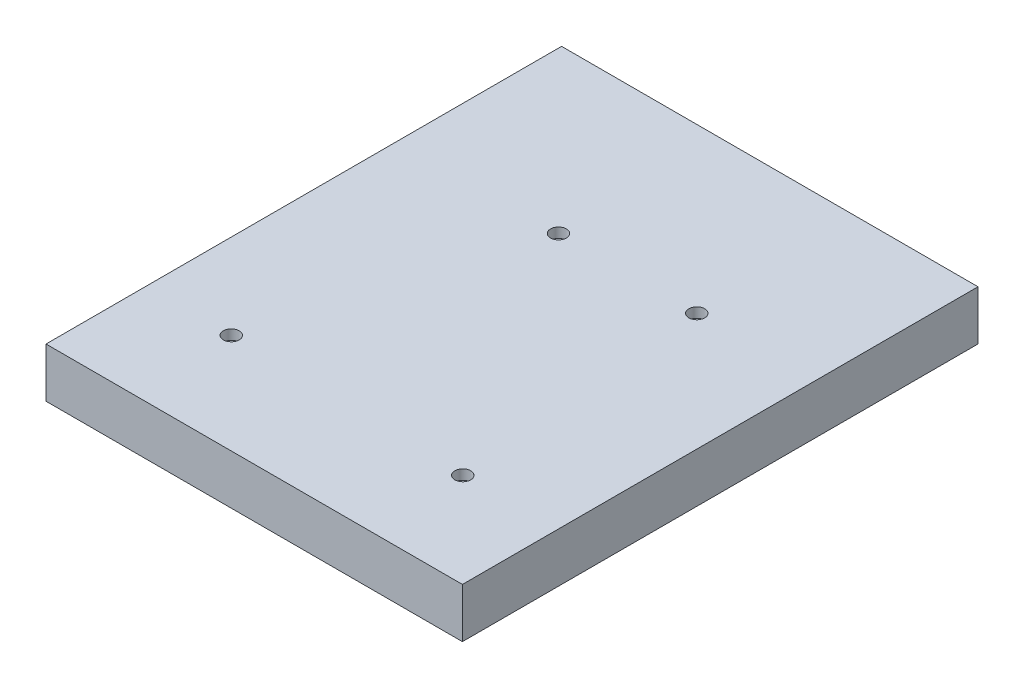
from build123d import *

# Parameters (mm, degrees)
SKETCH1_W           = 84
SKETCH1_H           = 104
BOSS_EXTRUDE1_DEPTH = 20
SKETCH2_W           = 82
SKETCH2_H           = 102
CUT_EXTRUDE1_DEPTH  = 5
SKETCH3_W           = 74
SKETCH3_H           = 94
CUT_EXTRUDE2_DEPTH  = 10
SKETCH4_W           = 37.72
SKETCH4_H           = 10
CUT_EXTRUDE4_DEPTH  = 6
SKETCH6_W           = 15
SKETCH6_H           = 10
SKETCH6_W_2         = 10
CUT_EXTRUDE6_DEPTH  = 10
SKETCH7_R           = 1.6
CUT_EXTRUDE7_DEPTH  = 2
SKETCH9_W           = 104
SKETCH9_H           = 10
CUT_EXTRUDE8_DEPTH  = 85


with BuildPart() as part:
    # Sketch1 → Boss-Extrude1 (new body)
    with BuildSketch(Plane(origin=(0, 0, 0), x_dir=(1, 0, 0), z_dir=(0, 1, 0))):
        Rectangle(SKETCH1_W, SKETCH1_H)
    extrude(amount=BOSS_EXTRUDE1_DEPTH)

    # Sketch2 → Cut-Extrude1 (cut)
    with BuildSketch(Plane(origin=(0, 0, 0), x_dir=(-1, 0, 0), z_dir=(0, -1, 0))):
        Rectangle(SKETCH2_W, SKETCH2_H)
    extrude(amount=-CUT_EXTRUDE1_DEPTH, mode=Mode.SUBTRACT)

    # Sketch3 → Cut-Extrude2 (cut)
    with BuildSketch(Plane(origin=(0, 20, 0), x_dir=(1, 0, 0), z_dir=(0, 1, 0))):
        Rectangle(SKETCH3_W, SKETCH3_H)
    extrude(amount=-CUT_EXTRUDE2_DEPTH, mode=Mode.SUBTRACT)

    # Sketch4 → Cut-Extrude4 (cut, through all)
    with BuildSketch(Plane.XY.offset(-47)):
        with Locations((0, 15)):
            Rectangle(SKETCH4_W, SKETCH4_H)
    extrude(amount=-CUT_EXTRUDE4_DEPTH, mode=Mode.SUBTRACT)

    # Sketch6 → Cut-Extrude6 (cut)
    with BuildSketch(Plane(origin=(0, 0, 47), x_dir=(-1, 0, 0), z_dir=(0, 0, -1))):
        with Locations((11.15, 15)):
            Rectangle(SKETCH6_W, SKETCH6_H)
        with Locations((-17.35, 15)):
            Rectangle(SKETCH6_W_2, SKETCH6_H)
    extrude(amount=-CUT_EXTRUDE6_DEPTH, mode=Mode.SUBTRACT)

    # Sketch7 → Cut-Extrude7 (cut)
    with BuildSketch(Plane(origin=(0, 10, 0), x_dir=(1, 0, 0), z_dir=(0, 1, 0))):
        with Locations((18.275, 19)):
            Circle(SKETCH7_R)
        with Locations((-24.825, -31.8)):
            Circle(SKETCH7_R)
        with Locations((22.975, -32.9)):
            Circle(SKETCH7_R)
        with Locations((-9.625, 19)):
            Circle(SKETCH7_R)
    extrude(amount=-CUT_EXTRUDE7_DEPTH, mode=Mode.SUBTRACT)

    # Sketch9 → Cut-Extrude8 (cut, through all)
    with BuildSketch(Plane.ZY.offset(42)):
        with Locations((0, 15)):
            Rectangle(SKETCH9_W, SKETCH9_H)
    extrude(amount=-CUT_EXTRUDE8_DEPTH, mode=Mode.SUBTRACT)


solid = part.part
